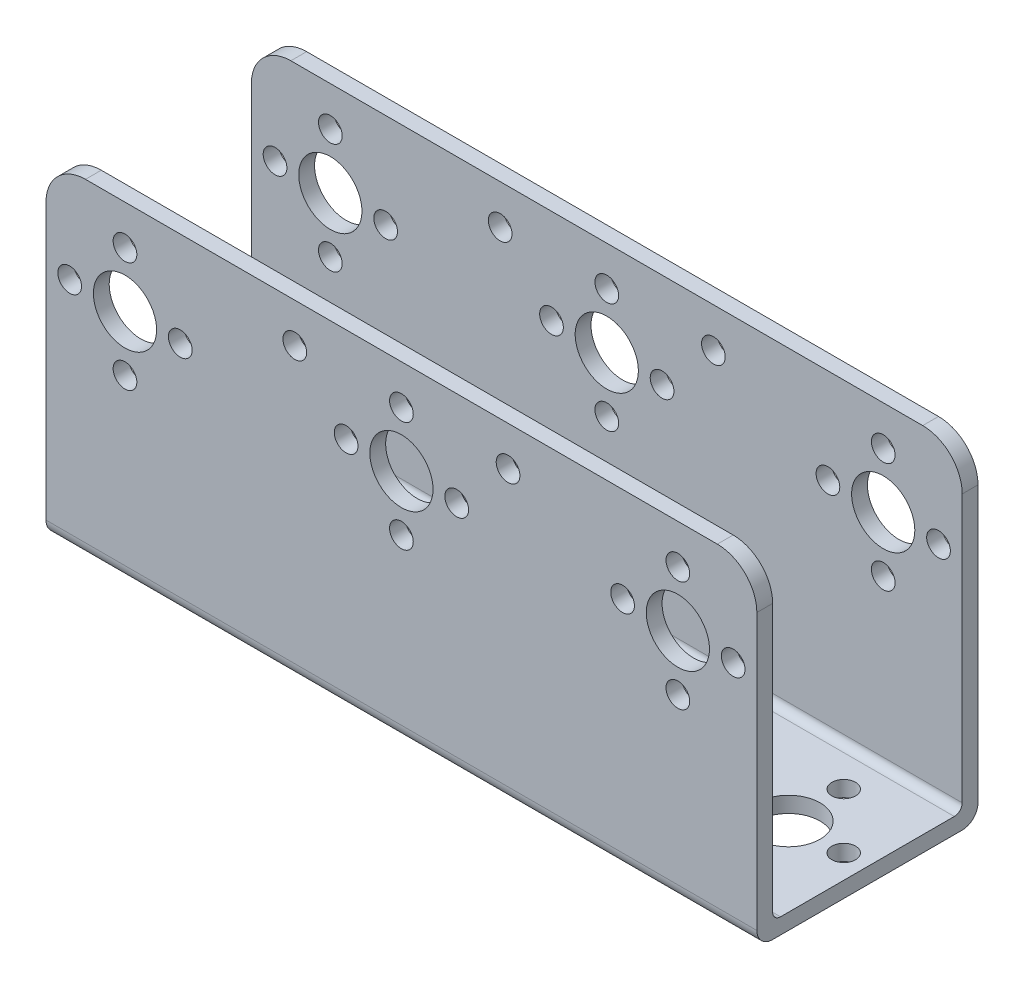
from build123d import *

# Parameters (mm, degrees)
ESTRUSIONE_ESTRUSIONE1_DEPTH = 2
SCHIZZO2_W                   = 90
SCHIZZO2_H                   = 28
ESTRUSIONE_ESTRUSIONE2_DEPTH = 2
ESTRUSIONE_ESTRUSIONE3_DEPTH = 2
SCHIZZO5_R                   = 4
SCHIZZO5_R_2                 = 1.5
TAGLIO_ESTRUSIONE1_DEPTH     = 29
RACCORDO1_R                  = 2
RACCORDO2_R                  = 2
RACCORDO3_R                  = 1
RACCORDO4_R                  = 1
SCHIZZO6_R                   = 4
SCHIZZO6_R_2                 = 1.5
TAGLIO_ESTRUSIONE2_DEPTH     = 42.860465116
SKETCH1_R                    = 1.5
CUT_EXTRUDE1_DEPTH           = 1
CUT_EXTRUDE1_DEPTH_BACK      = 29


with BuildPart() as part:
    # Schizzo1 → Estrusione-Estrusione1 (new body)
    with BuildSketch(Plane.XY):
        with BuildLine():
            Line((0, 0), (90, 0))
            Line((90, 0), (90, 36.860465116))
            ThreePointArc((90, 36.860465116), (88.535533906, 40.395999022), (85, 41.860465116))
            Line((85, 41.860465116), (5, 41.860465116))
            ThreePointArc((5, 41.860465116), (1.464466094, 40.395999022), (0, 36.860465116))
            Line((0, 36.860465116), (0, 0))
        make_face()
    extrude(amount=-ESTRUSIONE_ESTRUSIONE1_DEPTH)

    # Schizzo2 → Estrusione-Estrusione2 (add)
    with BuildSketch(Plane(origin=(0, 0, 0), x_dir=(1, 0, 0), z_dir=(0, 1, 0))):
        with Locations((45, 14)):
            Rectangle(SCHIZZO2_W, SCHIZZO2_H)
    extrude(amount=ESTRUSIONE_ESTRUSIONE2_DEPTH)

    # Schizzo4 → Estrusione-Estrusione3 (add)
    with BuildSketch(Plane.XY.offset(-28)):
        with BuildLine():
            Line((90, 0), (90, 36.860465116))
            ThreePointArc((90, 36.860465116), (88.535533906, 40.395999022), (85, 41.860465116))
            Line((85, 41.860465116), (5, 41.860465116))
            ThreePointArc((5, 41.860465116), (1.464466094, 40.395999022), (0, 36.860465116))
            Line((0, 36.860465116), (0, 0))
            Line((0, 0), (90, 0))
        make_face()
    extrude(amount=ESTRUSIONE_ESTRUSIONE3_DEPTH)

    # Schizzo5 → Taglio-Estrusione1 (cut, through all)
    with BuildSketch(Plane.XY):
        with Locations((10, 29.860465116)):
            Circle(SCHIZZO5_R)
        with Locations((45, 29.860465116)):
            Circle(SCHIZZO5_R)
        with Locations((80, 29.860465116)):
            Circle(SCHIZZO5_R)
        with Locations((10, 36.860465116)):
            Circle(SCHIZZO5_R_2)
        with Locations((3, 29.860465116)):
            Circle(SCHIZZO5_R_2)
        with Locations((10, 22.860465116)):
            Circle(SCHIZZO5_R_2)
        with Locations((17, 29.860465116)):
            Circle(SCHIZZO5_R_2)
        with Locations((38, 29.860465116)):
            Circle(SCHIZZO5_R_2)
        with Locations((45, 36.860465116)):
            Circle(SCHIZZO5_R_2)
        with Locations((80, 36.860465116)):
            Circle(SCHIZZO5_R_2)
        with Locations((73, 29.860465116)):
            Circle(SCHIZZO5_R_2)
        with Locations((45, 22.860465116)):
            Circle(SCHIZZO5_R_2)
        with Locations((80, 22.860465116)):
            Circle(SCHIZZO5_R_2)
        with Locations((87, 29.860465116)):
            Circle(SCHIZZO5_R_2)
        with Locations((52, 29.860465116)):
            Circle(SCHIZZO5_R_2)
    extrude(amount=-TAGLIO_ESTRUSIONE1_DEPTH, mode=Mode.SUBTRACT)

    # Raccordo1
    raccordo1_edges = [part.edges().sort_by_distance(p)[0] for p in [
        (45, 0, -28),
    ]]
    fillet(raccordo1_edges, radius=RACCORDO1_R)

    # Raccordo2
    raccordo2_edges = [part.edges().sort_by_distance(p)[0] for p in [
        (45, 0, 0),
    ]]
    fillet(raccordo2_edges, radius=RACCORDO2_R)

    # Raccordo3
    raccordo3_edges = [part.edges().sort_by_distance(p)[0] for p in [
        (45, 2, -2),
    ]]
    fillet(raccordo3_edges, radius=RACCORDO3_R)

    # Raccordo4
    raccordo4_edges = [part.edges().sort_by_distance(p)[0] for p in [
        (45, 2, -26),
    ]]
    fillet(raccordo4_edges, radius=RACCORDO4_R)

    # Schizzo6 → Taglio-Estrusione2 (cut, through all)
    with BuildSketch(Plane(origin=(0, 0, 0), x_dir=(1, 0, 0), z_dir=(0, 1, 0))):
        with Locations((45, 14)):
            Circle(SCHIZZO6_R)
        with Locations((10, 14)):
            Circle(SCHIZZO6_R)
        with Locations((80, 14)):
            Circle(SCHIZZO6_R)
        with Locations((10, 21)):
            Circle(SCHIZZO6_R_2)
        with Locations((3, 14)):
            Circle(SCHIZZO6_R_2)
        with Locations((10, 7)):
            Circle(SCHIZZO6_R_2)
        with Locations((17, 14)):
            Circle(SCHIZZO6_R_2)
        with Locations((38, 14)):
            Circle(SCHIZZO6_R_2)
        with Locations((45, 21)):
            Circle(SCHIZZO6_R_2)
        with Locations((80, 21)):
            Circle(SCHIZZO6_R_2)
        with Locations((80, 7)):
            Circle(SCHIZZO6_R_2)
        with Locations((45, 7)):
            Circle(SCHIZZO6_R_2)
        with Locations((52, 14)):
            Circle(SCHIZZO6_R_2)
        with Locations((87, 14)):
            Circle(SCHIZZO6_R_2)
        with Locations((73, 14)):
            Circle(SCHIZZO6_R_2)
    extrude(amount=TAGLIO_ESTRUSIONE2_DEPTH, mode=Mode.SUBTRACT)

    # Sketch1 → Cut-Extrude1 (cut, two sides)
    with BuildSketch(Plane.XY) as cut_extrude1_sk:
        with Locations((31.5, 36.860465116)):
            Circle(SKETCH1_R)
        with Locations((58.5, 36.860465116)):
            Circle(SKETCH1_R)
    extrude(amount=CUT_EXTRUDE1_DEPTH, mode=Mode.SUBTRACT)
    extrude(cut_extrude1_sk.sketch, amount=-CUT_EXTRUDE1_DEPTH_BACK, mode=Mode.SUBTRACT)


solid = part.part
